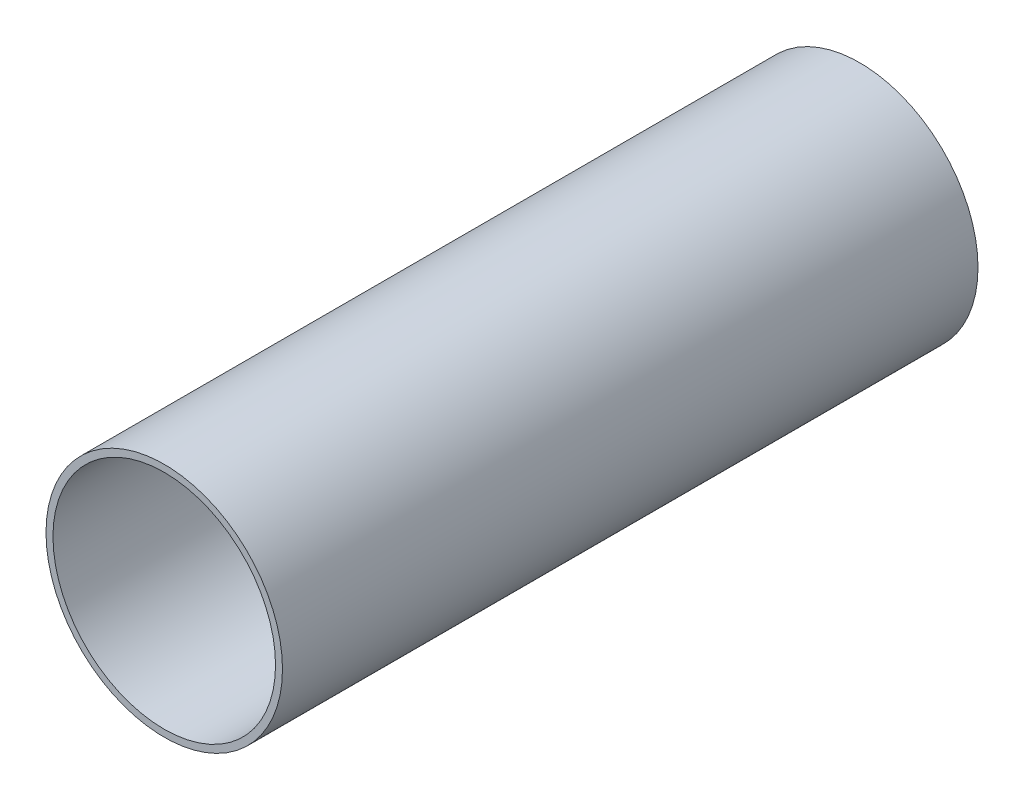
from build123d import *

# Parameters (mm, degrees)
SKETCH1_R           = 4.25
SKETCH1_R_2         = 4
BOSS_EXTRUDE1_DEPTH = 25


with BuildPart() as part:
    # Sketch1 → Boss-Extrude1 (new body)
    with BuildSketch(Plane.XY):
        Circle(SKETCH1_R)
        Circle(SKETCH1_R_2, mode=Mode.SUBTRACT)
    extrude(amount=BOSS_EXTRUDE1_DEPTH)


solid = part.part
